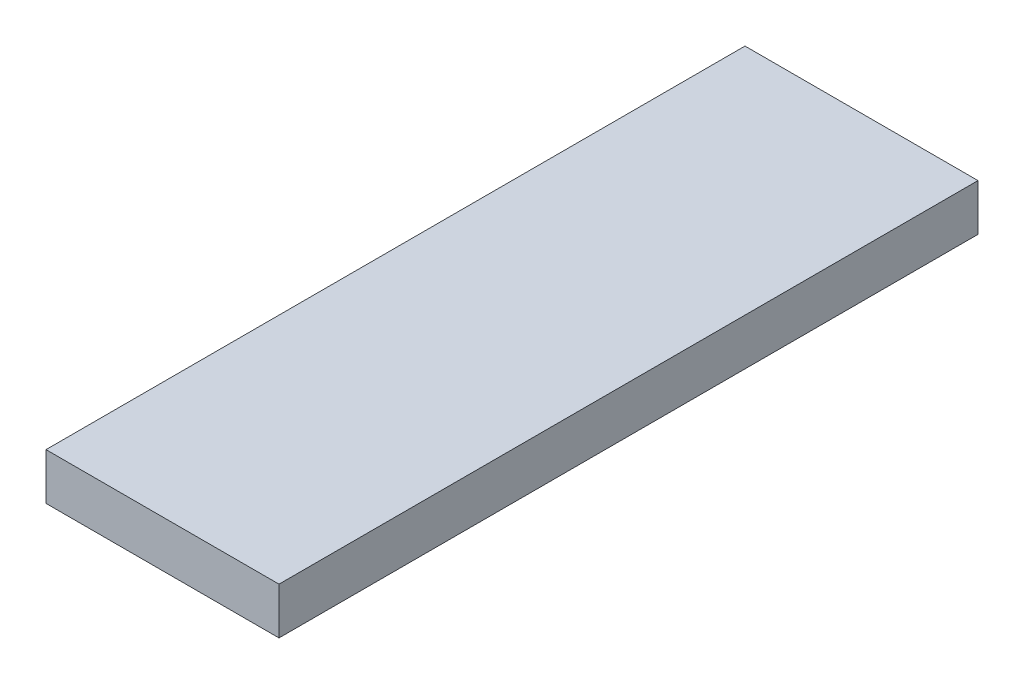
from build123d import *

# Parameters (mm, degrees)
SKETCH1_W           = 10
SKETCH1_H           = 2
BOSS_EXTRUDE1_DEPTH = 30


with BuildPart() as part:
    # Sketch1 → Boss-Extrude1 (new body)
    with BuildSketch(Plane.XY):
        Rectangle(SKETCH1_W, SKETCH1_H)
    extrude(amount=BOSS_EXTRUDE1_DEPTH)


solid = part.part
